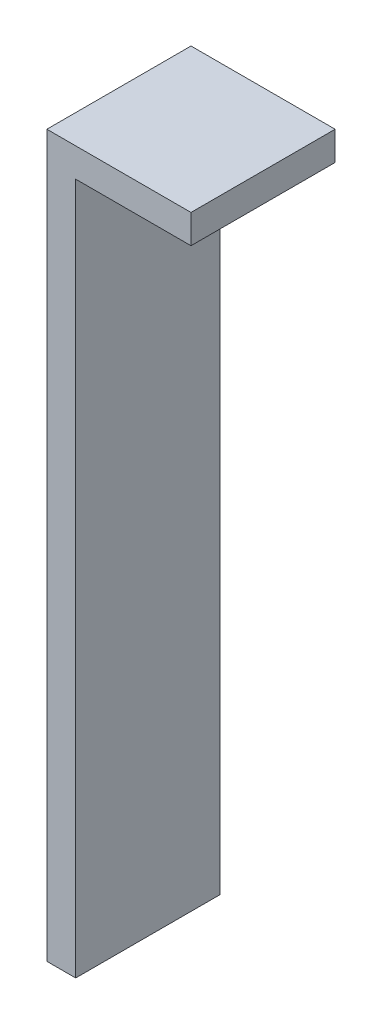
from build123d import *

# Parameters (mm, degrees)
BOSS_EXTRUDE1_DEPTH = 0.5


with BuildPart() as part:
    # Sketch1 → Boss-Extrude1 (new body, symmetric)
    with BuildSketch(Plane.XY):
        Polygon((0, 0), (-1, 0), (-1, -5), (-0.8, -5), (-0.8, -0.2), (0, -0.2), align=None)
    extrude(amount=BOSS_EXTRUDE1_DEPTH, both=True)


solid = part.part
